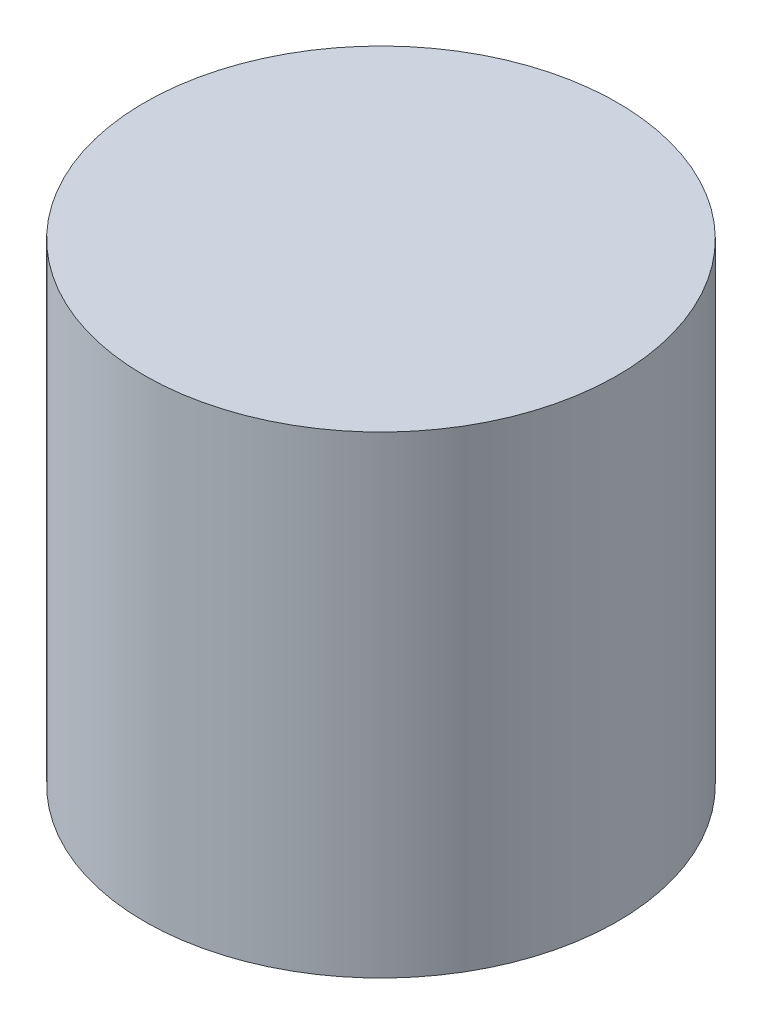
from build123d import *

# Parameters (mm, degrees)
M3X0_5_TAPPED_HOLE2_D     = 2.5
M3X0_5_TAPPED_HOLE2_DEPTH = 4.87
M3X0_5_TAPPED_HOLE2_TIP   = 0.751075774


with BuildPart() as part:
    # Sketch2 → Revolve1 (revolve)
    with BuildSketch(Plane(origin=(0, 0, 0), x_dir=(0, 0, -1), z_dir=(1, 0, 0))):
        Polygon((-5, -12), (-6, -12), (-6, 0), (0, 0), (0, -8.373661293), (-1.5, -8.373661293), (-5.055003164, -9.000504267), align=None)
    revolve(axis=Axis((0, 88.13248411, 0), (0, -1, 0)))

    # M3x0.5 Tapped Hole2
    with Locations(Plane(origin=(0, -8.373661293, 0), x_dir=(-1, 0, 0), z_dir=(0, -1, 0))):
        with Locations((0, 0)):
            Hole(M3X0_5_TAPPED_HOLE2_D / 2, depth=M3X0_5_TAPPED_HOLE2_DEPTH)
            with Locations((0, 0, -(M3X0_5_TAPPED_HOLE2_DEPTH + M3X0_5_TAPPED_HOLE2_TIP / 2))):  # 118° drill point
                Cone(0, M3X0_5_TAPPED_HOLE2_D / 2, M3X0_5_TAPPED_HOLE2_TIP, mode=Mode.SUBTRACT)


solid = part.part
